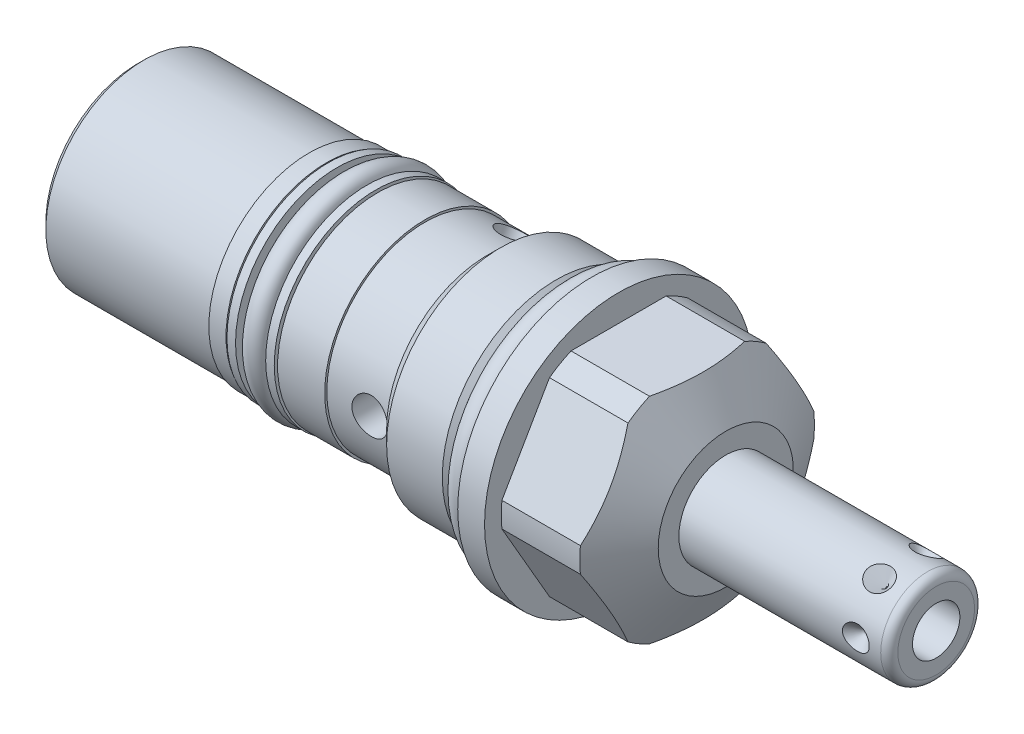
from build123d import *

# Parameters (mm, degrees)
SKETCH2_OUTSIDE_W  = 50.328
SKETCH2_OUTSIDE_H  = 50.328
CUT_EXTRUDE1_DEPTH = 12.7
CIRPATTERN1_COUNT  = 6
SKETCH6_W          = 13.716
SKETCH6_H          = 0.254
SKETCH7_R          = 0.8001
CUT_EXTRUDE2_DEPTH = 0.762
SKETCH8_W          = 6.1087
SKETCH8_H          = 2.0447
SKETCH9_W          = 1.016
SKETCH9_H          = 2.1844
SKETCH10_W         = 2.1082
SKETCH10_H         = 10.82675
CIRPATTERN2_COUNT  = 3
CHAMFER1_SIZE      = 0.762
SKETCH11_R         = 1.4732
SKETCH12_R         = 1.3081


with BuildPart() as part:
    # Sketch1 → Revolve1 (revolve)
    with BuildSketch(Plane.XY, mode=Mode.PRIVATE) as revolve1_sk:
        Polygon((0, 15.875), (3.175, 15.875), (3.175, 13.8938), (12.472790334, 13.8938), (15.875, 8.001), (15.875, 0), (-53.7972, 0), (-53.7972, 11.6205), (-12.4206, 11.6205), (-12.4206, 11.8745), (-10.80135, 13.49375), (-4.21005, 13.49375), (-2.7178, 12.0015), (0, 12.0015), align=None)
    revolve(revolve1_sk.sketch.rotate(Axis((0, 0, 0), (1, 0, 0)), 90), axis=Axis((0, 0, 0), (1, 0, 0)))  # turned: the seam where the file's is

    # Sketch2 outside → Cut-Extrude1 (cut)
    with BuildSketch(Plane(origin=(15.875, 0, 0), x_dir=(0, 0, -1), z_dir=(1, 0, 0))):
        Rectangle(SKETCH2_OUTSIDE_W, SKETCH2_OUTSIDE_H)
        Polygon((7.332348419, 12.7), (-7.332348419, 12.7), (-14.664696837, 0), (-7.332348419, -12.7), (7.332348419, -12.7), (14.664696837, 0), align=None, mode=Mode.SUBTRACT)
    extrude(amount=-CUT_EXTRUDE1_DEPTH, mode=Mode.SUBTRACT)

    # Sketch3 → Revolve2 (revolve)
    with BuildSketch(Plane.XY, mode=Mode.PRIVATE) as revolve2_sk:
        with BuildLine():
            Line((15.875, 5.55625), (39.7764, 5.55625))
            ThreePointArc((39.7764, 5.55625), (40.49482049, 5.25867049), (40.7924, 4.54025))
            Line((40.7924, 4.54025), (40.7924, 0))
            Line((40.7924, 0), (15.875, 0))
            Line((15.875, 0), (15.875, 5.55625))
        make_face()
    revolve(revolve2_sk.sketch.rotate(Axis((0, 0, 0), (1, 0, 0)), 90), axis=Axis((0, 0, 0), (1, 0, 0)))  # turned: the seam where the file's is

    # Sketch4 → Cut-Revolve1 (revolve, cut)
    with BuildSketch(Plane(origin=(0, 0, 0), x_dir=(1, 0, 0), z_dir=(0, 1, 0)), mode=Mode.PRIVATE) as cut_revolve1_sk:
        Polygon((38.4175, 5.55625), (36.83, 5.55625), (36.83, 3.96875), align=None)
    cut_revolve1 = revolve(cut_revolve1_sk.sketch.rotate(Axis((36.83, 0, -10.073804773), (0, 0, 1)), 180), axis=Axis((36.83, 0, -10.073804773), (0, 0, 1)), mode=Mode.SUBTRACT)  # turned: the seam where the file's is

    # CirPattern1: Cut-Revolve1 ×6 about axis
    cirpattern1_axis = Axis((0, 0, 0), (-1, 0, 0))
    for i in range(1, CIRPATTERN1_COUNT):
        add(cut_revolve1.rotate(cirpattern1_axis, i * 360 / CIRPATTERN1_COUNT), mode=Mode.SUBTRACT)

    # Sketch5 → Cut-Revolve2 (revolve, cut)
    with BuildSketch(Plane.XY, mode=Mode.PRIVATE) as cut_revolve2_sk:
        Polygon((40.7924, 2.8067), (30.6324, 2.8067), (28.945964501, 0), (40.7924, 0), align=None)
    revolve(cut_revolve2_sk.sketch.rotate(Axis((0, 0, 0), (1, 0, 0)), 90), axis=Axis((0, 0, 0), (1, 0, 0)), mode=Mode.SUBTRACT)  # turned: the seam where the file's is

    # Sketch6 → Revolve3 (revolve)
    with BuildSketch(Plane.XY, mode=Mode.PRIVATE) as revolve3_sk:
        with Locations((-26.6192, 11.7475)):
            Rectangle(SKETCH6_W, SKETCH6_H)
    revolve(revolve3_sk.sketch.rotate(Axis((0, 0, 0), (-1, 0, 0)), 270), axis=Axis((0, 0, 0), (-1, 0, 0)))  # turned: the seam where the file's is

    # Sketch7 → Cut-Extrude2 (cut)
    with BuildSketch(Plane.ZY.offset(53.7972)):
        Circle(SKETCH7_R)
    extrude(amount=-CUT_EXTRUDE2_DEPTH, mode=Mode.SUBTRACT)

    # Sketch8 → Cut-Revolve3 (revolve, cut)
    with BuildSketch(Plane.XY, mode=Mode.PRIVATE) as cut_revolve3_sk:
        with Locations((-28.39085, 10.85215)):
            Rectangle(SKETCH8_W, SKETCH8_H)
    revolve(cut_revolve3_sk.sketch.rotate(Axis((0, 0, 0), (-1, 0, 0)), 270), axis=Axis((0, 0, 0), (-1, 0, 0)), mode=Mode.SUBTRACT)  # turned: the seam where the file's is

    # Sketch9 → Revolve4 (revolve)
    with BuildSketch(Plane.XY, mode=Mode.PRIVATE) as revolve4_sk:
        with Locations((-26.0985, 10.922)):
            Rectangle(SKETCH9_W, SKETCH9_H)
        with Locations((-30.6832, 10.922)):
            Rectangle(SKETCH9_W, SKETCH9_H)
    revolve(revolve4_sk.sketch.rotate(Axis((0, 0, 0), (-1, 0, 0)), 270), axis=Axis((0, 0, 0), (-1, 0, 0)))  # turned: the seam where the file's is

    # Sketch10 → Cut-Revolve4 (revolve, cut)
    with BuildSketch(Plane(origin=(0, 0, 0), x_dir=(1, 0, 0), z_dir=(0, 1, 0))):
        with Locations((-15.7353, -6.207125)):
            Rectangle(SKETCH10_W, SKETCH10_H)
    cut_revolve4 = revolve(axis=Axis((-14.6812, 0, -23.036850257), (0, 0, 1)), mode=Mode.SUBTRACT)

    # CirPattern2: Cut-Revolve4 ×3 about axis
    cirpattern2_axis = Axis((0, 0, 0), (1, 0, 0))
    for i in range(1, CIRPATTERN2_COUNT):
        add(cut_revolve4.rotate(cirpattern2_axis, i * 360 / CIRPATTERN2_COUNT), mode=Mode.SUBTRACT)

    # Chamfer1
    chamfer1_edges = [part.edges().sort_by_distance(p)[0] for p in [
        (-53.7972, 0, -11.6205),
    ]]
    chamfer(chamfer1_edges, length=CHAMFER1_SIZE)

    # Sketch13 → Cut-Revolve5 (revolve, cut)
    with BuildSketch(Plane.XY, mode=Mode.PRIVATE) as cut_revolve5_sk:
        Polygon((-53.7972, 4.572), (-51.7144, 4.129287193), (-51.039512807, 3.4544), (-42.0116, 3.4544), (-42.0116, 0), (-53.7972, 0), align=None)
    revolve(cut_revolve5_sk.sketch.rotate(Axis((-63.275446536, 0, 0), (1, 0, 0)), 90), axis=Axis((-63.275446536, 0, 0), (1, 0, 0)), mode=Mode.SUBTRACT)  # turned: the seam where the file's is


with BuildPart() as body_2:
    # Sketch11 → Revolve5 (revolve)
    with BuildSketch(Plane.XY, mode=Mode.PRIVATE) as revolve5_sk:
        with Locations((-1.4732, 13.4747)):
            Circle(SKETCH11_R)
    revolve(revolve5_sk.sketch.rotate(Axis((0, 0, 0), (1, 0, 0)), 90), axis=Axis((0, 0, 0), (1, 0, 0)))  # turned: the seam where the file's is


with BuildPart() as body_3:
    # Sketch12 → Revolve7 (revolve)
    with BuildSketch(Plane.XY, mode=Mode.PRIVATE) as revolve7_sk:
        with Locations((-28.39085, 11.1379)):
            Circle(SKETCH12_R)
    revolve(revolve7_sk.sketch.rotate(Axis((0, 0, 0), (-1, 0, 0)), 270), axis=Axis((0, 0, 0), (-1, 0, 0)))  # turned: the seam where the file's is


solid = Compound([part.part, body_2.part, body_3.part])
